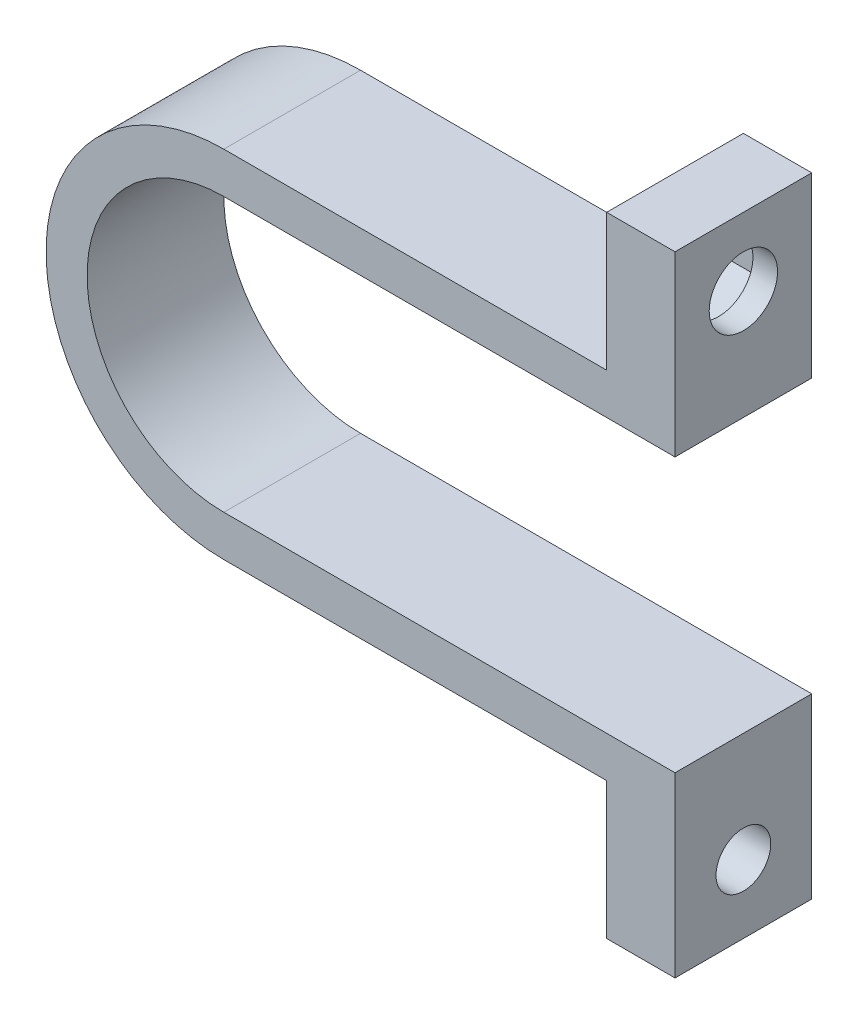
from build123d import *

# Parameters (mm, degrees)
EXTRUDE_1_DEPTH     = 10
CUT_EXTRUDE_1_DEPTH = 3.2
SKETCH_3_R          = 2.5
CUT_EXTRUDE_2_DEPTH = 6
SKETCH_4_R          = 2
CUT_EXTRUDE_3_DEPTH = 6


with BuildPart() as part:
    # 草图1 → 凸台-拉伸1 (new body)
    with BuildSketch(Plane.XY):
        with BuildLine():
            Line((0, 13), (28, 13))
            Line((28, 13), (28, 23))
            Line((28, 23), (33, 23))
            Line((33, 23), (33, 10))
            Line((33, 10), (0, 10))
            ThreePointArc((0, 10), (-10, 0), (0, -10))
            Line((0, -10), (33, -10))
            Line((33, -10), (33, -23))
            Line((33, -23), (28, -23))
            Line((28, -23), (28, -13))
            Line((28, -13), (0, -13))
            ThreePointArc((0, -13), (-13, 0), (0, 13))
        make_face()
    extrude(amount=EXTRUDE_1_DEPTH)

    # 草图2 → 切除-拉伸1 (cut)
    with BuildSketch(Plane.ZY.offset(-28)):
        Polygon((8.5, 15.979274058), (8.5, 20.020725942), (5, 22.041451884), (1.5, 20.020725942), (1.5, 15.979274058), (5, 13.958548116), align=None)
    extrude(amount=-CUT_EXTRUDE_1_DEPTH, mode=Mode.SUBTRACT)

    # 草图3 → 切除-拉伸2 (cut, through all)
    with BuildSketch(Plane.ZY.offset(-28)):
        with Locations((5, 18)):
            Circle(SKETCH_3_R)
    extrude(amount=-CUT_EXTRUDE_2_DEPTH, mode=Mode.SUBTRACT)

    # 草图4 → 切除-拉伸3 (cut, through all)
    with BuildSketch(Plane.ZY.offset(-28)):
        with Locations((5, -18)):
            Circle(SKETCH_4_R)
    extrude(amount=-CUT_EXTRUDE_3_DEPTH, mode=Mode.SUBTRACT)


solid = part.part
